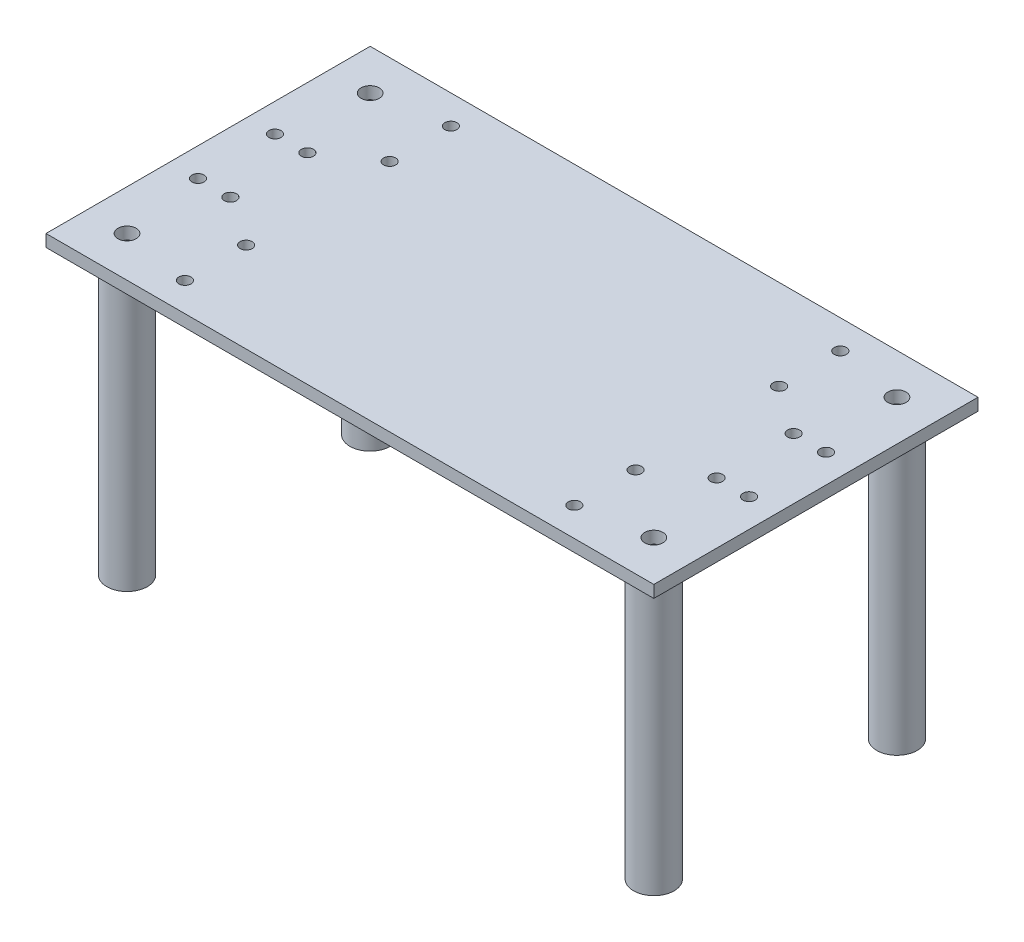
from build123d import *

# Parameters (mm, degrees)
SKETCH2_W           = 150
SKETCH2_H           = 80
SKETCH2_R           = 1.5
BOSS_EXTRUDE1_DEPTH = 3
SKETCH5_R           = 5
SKETCH5_R_2         = 2.5
BOSS_EXTRUDE3_DEPTH = 70
SKETCH7_R           = 1.5
CUT_EXTRUDE1_DEPTH  = 10
SKETCH3_R           = 2.25
CUT_EXTRUDE2_DEPTH  = 5


with BuildPart() as part:
    # Sketch2 → Boss-Extrude1 (new body)
    with BuildSketch(Plane(origin=(0, 0, 0), x_dir=(1, 0, 0), z_dir=(0, 1, 0))):
        with Locations((-8.46473029, 1.825726141)):
            Rectangle(SKETCH2_W, SKETCH2_H)
        with Locations((-68.46473029, 11.325726141)):
            Circle(SKETCH2_R, mode=Mode.SUBTRACT)
        with Locations((-68.46473029, -7.674273859)):
            Circle(SKETCH2_R, mode=Mode.SUBTRACT)
        with Locations((-76.46473029, 11.325726141)):
            Circle(SKETCH2_R, mode=Mode.SUBTRACT)
        with Locations((-76.46473029, -7.674273859)):
            Circle(SKETCH2_R, mode=Mode.SUBTRACT)
        with Locations((51.53526971, -7.674273859)):
            Circle(SKETCH2_R, mode=Mode.SUBTRACT)
        with Locations((59.53526971, -7.674273859)):
            Circle(SKETCH2_R, mode=Mode.SUBTRACT)
        with Locations((59.53526971, 11.325726141)):
            Circle(SKETCH2_R, mode=Mode.SUBTRACT)
        with Locations((51.53526971, 11.325726141)):
            Circle(SKETCH2_R, mode=Mode.SUBTRACT)
    extrude(amount=-BOSS_EXTRUDE1_DEPTH)

    # Sketch5 → Boss-Extrude3 (add)
    with BuildSketch(Plane.XZ.offset(3)):
        with Locations((-73.46473029, 28.174273859)):
            Circle(SKETCH5_R)
        with Locations((-73.46473029, 28.174273859)):
            Circle(SKETCH5_R_2, mode=Mode.SUBTRACT)
        with Locations((56.53526971, 28.174273859)):
            Circle(SKETCH5_R)
        with Locations((56.53526971, 28.174273859)):
            Circle(SKETCH5_R_2, mode=Mode.SUBTRACT)
        with Locations((56.53526971, -31.825726141)):
            Circle(SKETCH5_R)
        with Locations((56.53526971, -31.825726141)):
            Circle(SKETCH5_R_2, mode=Mode.SUBTRACT)
        with Locations((-73.46473029, -31.825726141)):
            Circle(SKETCH5_R)
        with Locations((-73.46473029, -31.825726141)):
            Circle(SKETCH5_R_2, mode=Mode.SUBTRACT)
    extrude(amount=BOSS_EXTRUDE3_DEPTH)

    # Sketch7 → Cut-Extrude1 (cut)
    with BuildSketch(Plane(origin=(0, 0, 0), x_dir=(1, 0, 0), z_dir=(0, 1, 0))):
        with Locations((-56.449797454, 34.724662311)):
            Circle(SKETCH7_R)
        with Locations((-56.449797454, 19.620815473)):
            Circle(SKETCH7_R)
        with Locations((39.655256431, 34.724662311)):
            Circle(SKETCH7_R)
        with Locations((39.655256431, 19.620815473)):
            Circle(SKETCH7_R)
        with Locations((-56.284289699, -15.969363191)):
            Circle(SKETCH7_R)
        with Locations((-56.284289699, -31.073210029)):
            Circle(SKETCH7_R)
        with Locations((39.820764186, -15.969363191)):
            Circle(SKETCH7_R)
        with Locations((39.820764186, -31.073210029)):
            Circle(SKETCH7_R)
    extrude(amount=-CUT_EXTRUDE1_DEPTH, mode=Mode.SUBTRACT)

    # Sketch3 → Cut-Extrude2 (cut)
    with BuildSketch(Plane(origin=(0, 0, 0), x_dir=(1, 0, 0), z_dir=(0, 1, 0))):
        with Locations((56.53526971, 31.825726141)):
            Circle(SKETCH3_R)
        with Locations((56.53526971, -28.174273859)):
            Circle(SKETCH3_R)
        with Locations((-73.46473029, -28.174273859)):
            Circle(SKETCH3_R)
        with Locations((-73.46473029, 31.825726141)):
            Circle(SKETCH3_R)
    extrude(amount=-CUT_EXTRUDE2_DEPTH, mode=Mode.SUBTRACT)


solid = part.part
